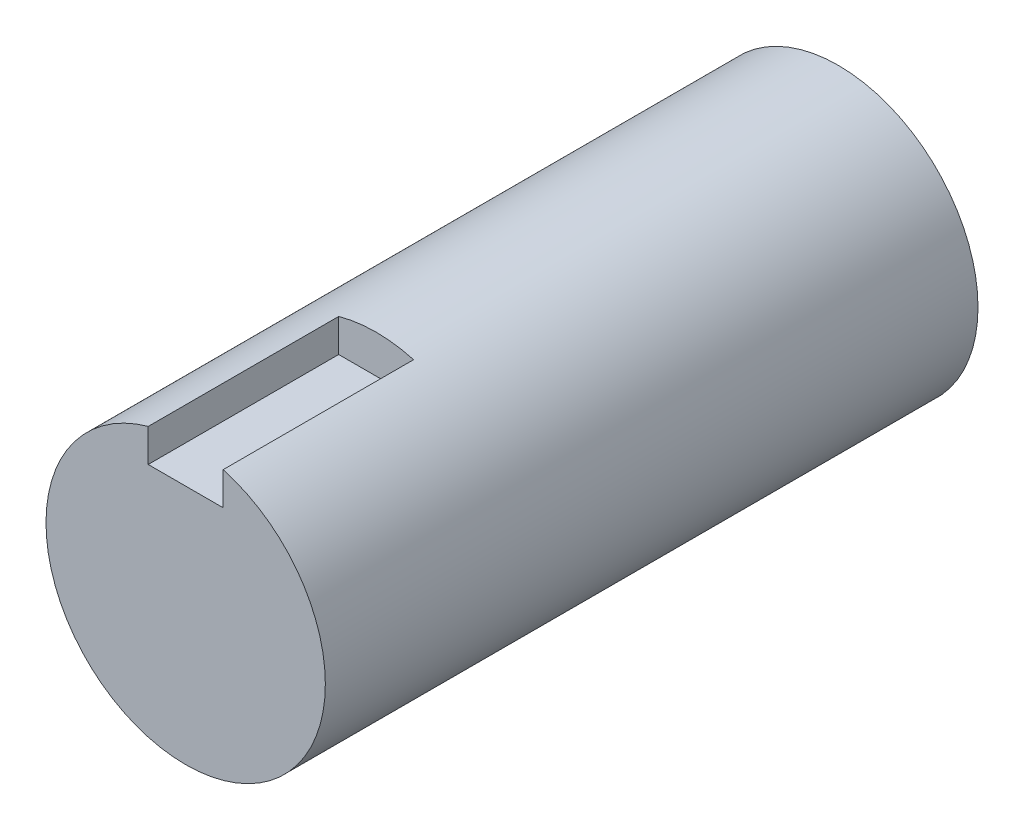
from build123d import *

# Parameters (mm, degrees)
SKETCH_1_R          = 11
EXTRUDE_1_DEPTH     = 51.4
SKETCH_2_W          = 15
SKETCH_2_H          = 3
CUT_EXTRUDE_1_DEPTH = 2.95


with BuildPart() as part:
    # 草图1 → 凸台-拉伸1 (new body)
    with BuildSketch(Plane.XY):
        Circle(SKETCH_1_R)
    extrude(amount=EXTRUDE_1_DEPTH)

    # 草图2 → 切除-拉伸1 (cut, symmetric)
    with BuildSketch(Plane(origin=(0, 0, 0), x_dir=(0, 0, -1), z_dir=(1, 0, 0))):
        with Locations((-43.9, 9.5)):
            Rectangle(SKETCH_2_W, SKETCH_2_H)
    extrude(amount=CUT_EXTRUDE_1_DEPTH, both=True, mode=Mode.SUBTRACT)


solid = part.part
